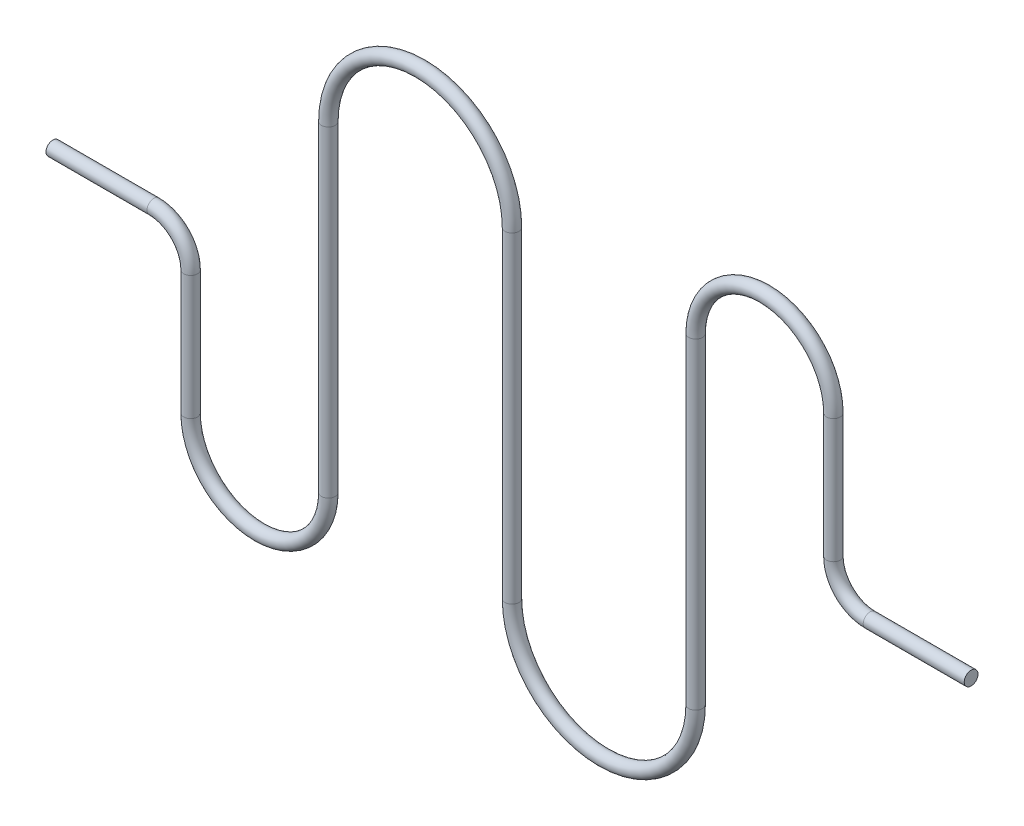
from build123d import *

# Parameters (mm, degrees)
SKETCH7_R = 1.905


with BuildPart() as part:
    # Sweep3: sweep along a path in Sketch4
    with BuildLine(Plane.XY) as sweep3_path:
        Line((-127, 0), (-99.06, 0))
        ThreePointArc((-99.06, 0), (-91.875795103, -2.975795103), (-88.9, -10.16))
        Line((-88.9, -10.16), (-88.9, -44.45))
        ThreePointArc((-88.9, -44.45), (-69.85, -63.5), (-50.8, -44.45))
        Line((-50.8, -44.45), (-50.8, 44.45))
        ThreePointArc((-50.8, 44.45), (-25.4, 69.85), (0, 44.45))
        Line((0, 44.45), (0, -44.45))
        ThreePointArc((0, -44.45), (25.4, -69.85), (50.8, -44.45))
        Line((50.8, -44.45), (50.8, 44.45))
        ThreePointArc((50.8, 44.45), (69.85, 63.5), (88.9, 44.45))
        Line((88.9, 44.45), (88.9, 10.16))
        ThreePointArc((88.9, 10.16), (91.875795103, 2.975795103), (99.06, 0))
        Line((99.06, 0), (127, 0))
    # Sketch7 → Sweep3 (sweep)
    with BuildSketch(Plane(origin=(127, 0, 0), x_dir=(0, 0, -1), z_dir=(1, 0, 0))):
        Circle(SKETCH7_R)
    sweep(path=sweep3_path.line)


solid = part.part
